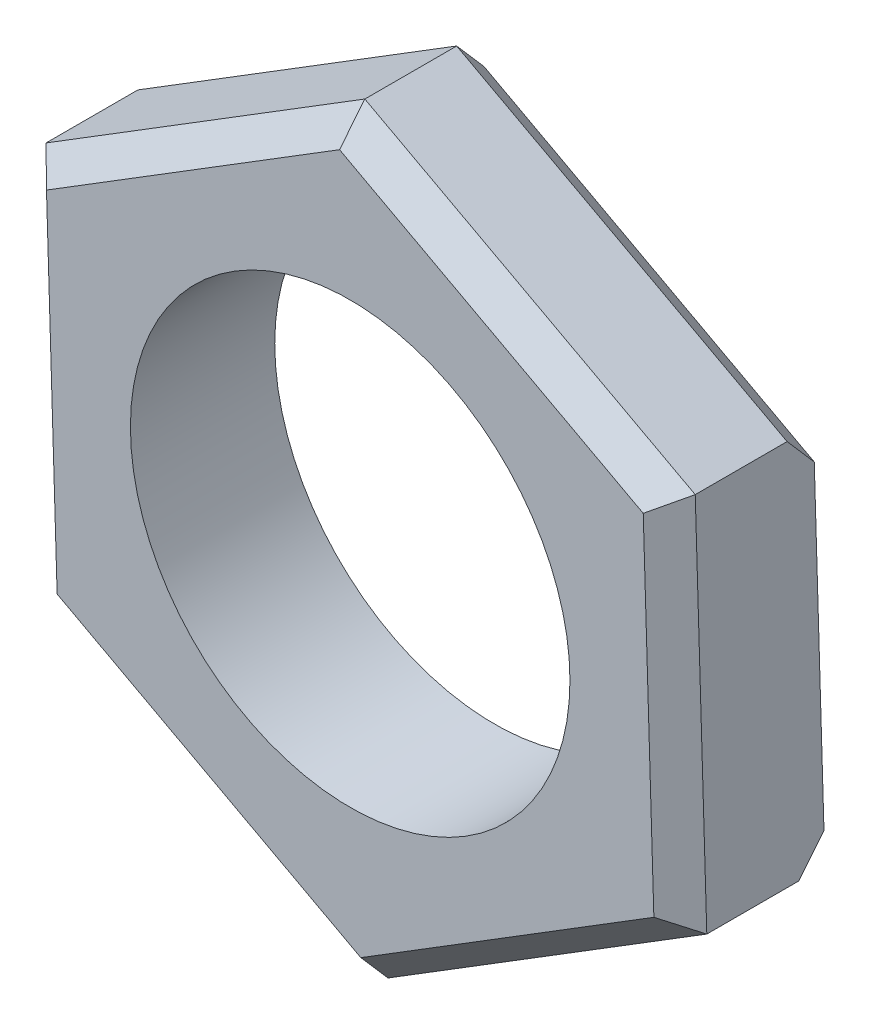
from build123d import *

# Parameters (mm, degrees)
SKETCH_1_R      = 3.35
EXTRUDE_1_DEPTH = 2.2
CHAMFER_1_SIZE  = 0.4


with BuildPart() as part:
    # 草图1 → 凸台-拉伸1 (new body)
    with BuildSketch(Plane.XY):
        Polygon((5.035878056, -2.703688629), (4.859402065, 3.009354013), (-0.176475992, 5.713042642), (-5.035878056, 2.703688629), (-4.859402065, -3.009354013), (0.176475992, -5.713042642), align=None)
        Circle(SKETCH_1_R, mode=Mode.SUBTRACT)
    extrude(amount=EXTRUDE_1_DEPTH)

    # 倒角1
    chamfer_1_edges = [part.edges().sort_by_distance(p)[0] for p in [
        (2.341463036, 4.361198327, 2.2),
        (-2.606177024, 4.208365635, 2.2),
        (-4.94764006, -0.152832692, 2.2),
        (-2.341463036, -4.361198327, 2.2),
        (2.606177024, -4.208365635, 2.2),
        (-2.341463036, -4.361198327, 0),
        (-4.94764006, -0.152832692, 0),
        (-2.606177024, 4.208365635, 0),
        (4.94764006, 0.152832692, 2.2),
        (2.341463036, 4.361198327, 0),
        (2.606177024, -4.208365635, 0),
    ]]
    chamfer(chamfer_1_edges, length=CHAMFER_1_SIZE)


solid = part.part
